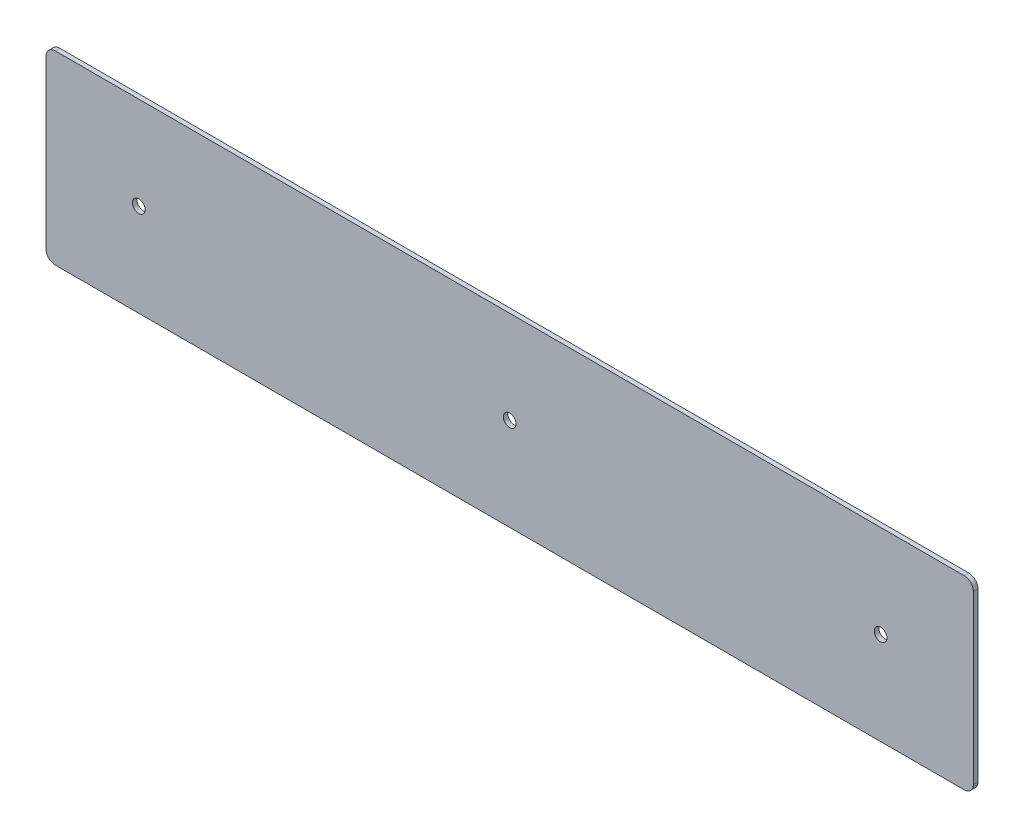
from build123d import *

# Parameters (mm, degrees)
SKETCH1_W           = 317.5
SKETCH1_H           = 63.5
SKETCH1_R           = 2.1828125
BOSS_EXTRUDE1_DEPTH = 0.79375
FILLET1_R           = 3.175


with BuildPart() as part:
    # Sketch1 → Boss-Extrude1 (new body, symmetric)
    with BuildSketch(Plane.XY):
        Rectangle(SKETCH1_W, SKETCH1_H)
        Circle(SKETCH1_R, mode=Mode.SUBTRACT)
        with Locations((127, 0)):
            Circle(SKETCH1_R, mode=Mode.SUBTRACT)
        with Locations((-127, 0)):
            Circle(SKETCH1_R, mode=Mode.SUBTRACT)
    extrude(amount=BOSS_EXTRUDE1_DEPTH, both=True)

    # Fillet1
    fillet1_edges = [part.edges().sort_by_distance(p)[0] for p in [
        (158.75, -31.75, 0),
        (-158.75, -31.75, 0),
        (-158.75, 31.75, 0),
        (158.75, 31.75, 0),
    ]]
    fillet(fillet1_edges, radius=FILLET1_R)


solid = part.part
